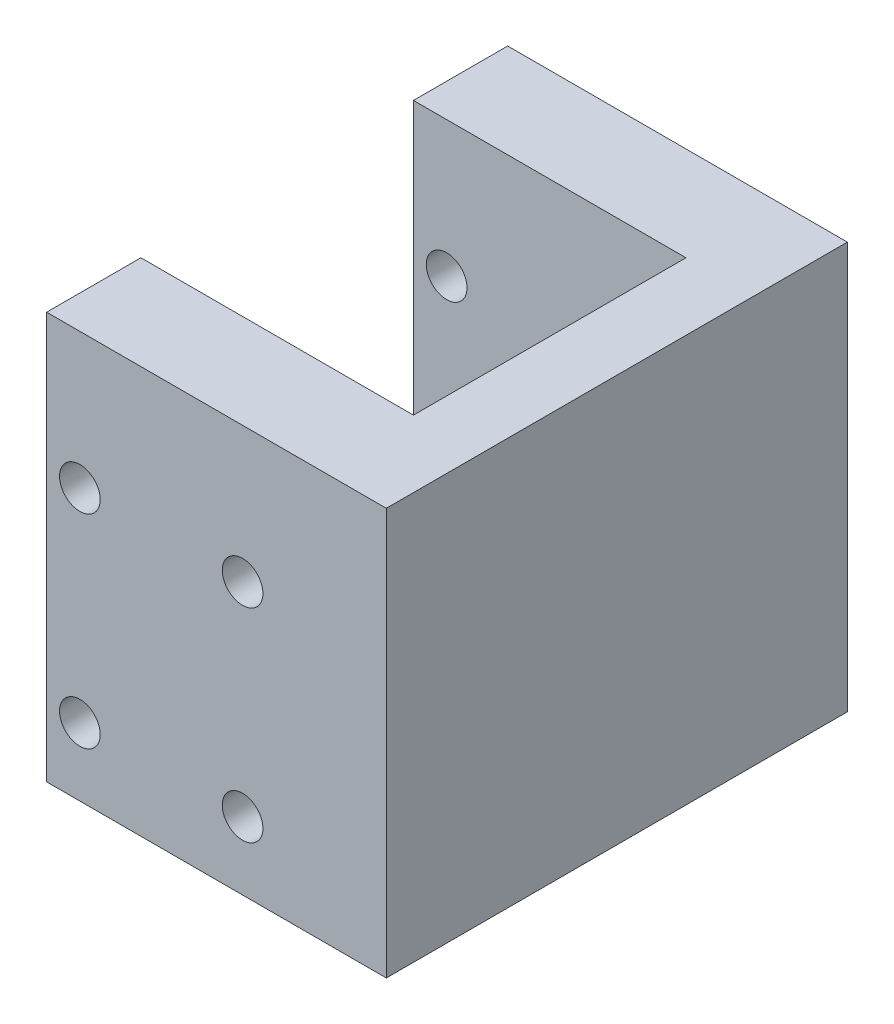
from build123d import *

# Parameters (mm, degrees)
EXTRUDE1_DEPTH     = 30
SKETCH3_R          = 1.5
CUT_EXTRUDE1_DEPTH = 30


with BuildPart() as part:
    # Sketch2 → Extrude1 (new body)
    with BuildSketch(Plane.XZ.offset(350)):
        Polygon((-380.315803698, -338.6), (-398.815803698, -338.6), (-398.815803698, -345.55), (-378.715803698, -345.55), (-378.715803698, -365.65), (-398.815803698, -365.65), (-398.815803698, -372.6), (-380.315803698, -372.6), (-373.765803698, -372.6), (-373.765803698, -338.6), align=None)
    extrude(amount=-EXTRUDE1_DEPTH)

    # Sketch3 → Cut-Extrude1 (cut)
    with BuildSketch(Plane.XY.offset(-338.6)):
        with Locations((-384.365803698, -345)):
            Circle(SKETCH3_R)
        with Locations((-396.365803698, -345)):
            Circle(SKETCH3_R)
        with Locations((-384.365803698, -330)):
            Circle(SKETCH3_R)
        with Locations((-396.365803698, -330)):
            Circle(SKETCH3_R)
    extrude(amount=-CUT_EXTRUDE1_DEPTH, mode=Mode.SUBTRACT)


solid = part.part
